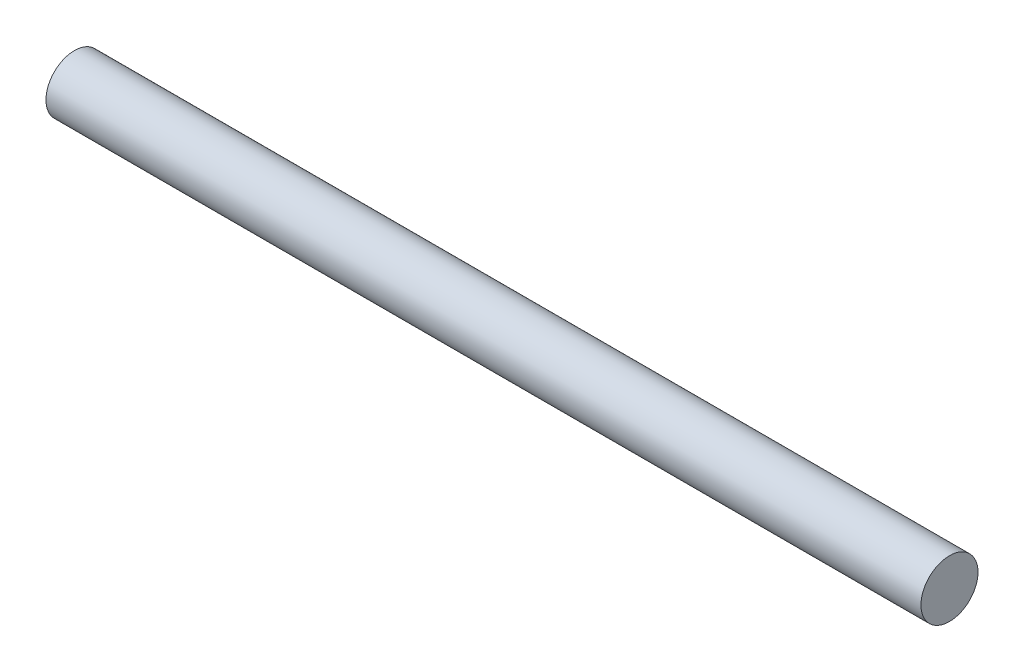
from build123d import *

# Parameters (mm, degrees)
SKETCH1_R           = 2.286
BOSS_EXTRUDE1_DEPTH = 70.104


with BuildPart() as part:
    # Sketch1 → Boss-Extrude1 (new body)
    with BuildSketch(Plane(origin=(0, 0, 0), x_dir=(0, 0, -1), z_dir=(1, 0, 0))):
        Circle(SKETCH1_R)
    extrude(amount=BOSS_EXTRUDE1_DEPTH)


solid = part.part
